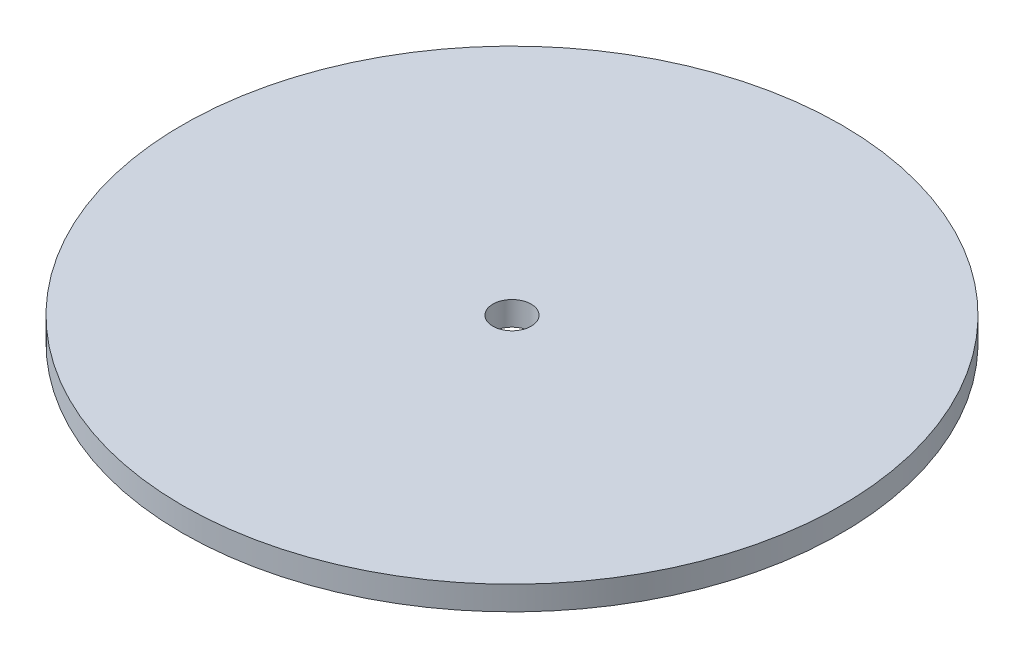
from build123d import *

# Parameters (mm, degrees)
SKETCH2_R           = 137.5
BOSS_EXTRUDE1_DEPTH = 10
SKETCH4_R           = 8
CUT_EXTRUDE1_DEPTH  = 11


with BuildPart() as part:
    # Sketch2 → Boss-Extrude1 (new body)
    with BuildSketch(Plane(origin=(0, 0, 0), x_dir=(1, 0, 0), z_dir=(0, 1, 0))):
        Circle(SKETCH2_R)
    extrude(amount=BOSS_EXTRUDE1_DEPTH)

    # Sketch4 → Cut-Extrude1 (cut, through all)
    with BuildSketch(Plane(origin=(0, 10, 0), x_dir=(1, 0, 0), z_dir=(0, 1, 0))):
        Circle(SKETCH4_R)
    extrude(amount=-CUT_EXTRUDE1_DEPTH, mode=Mode.SUBTRACT)


solid = part.part
